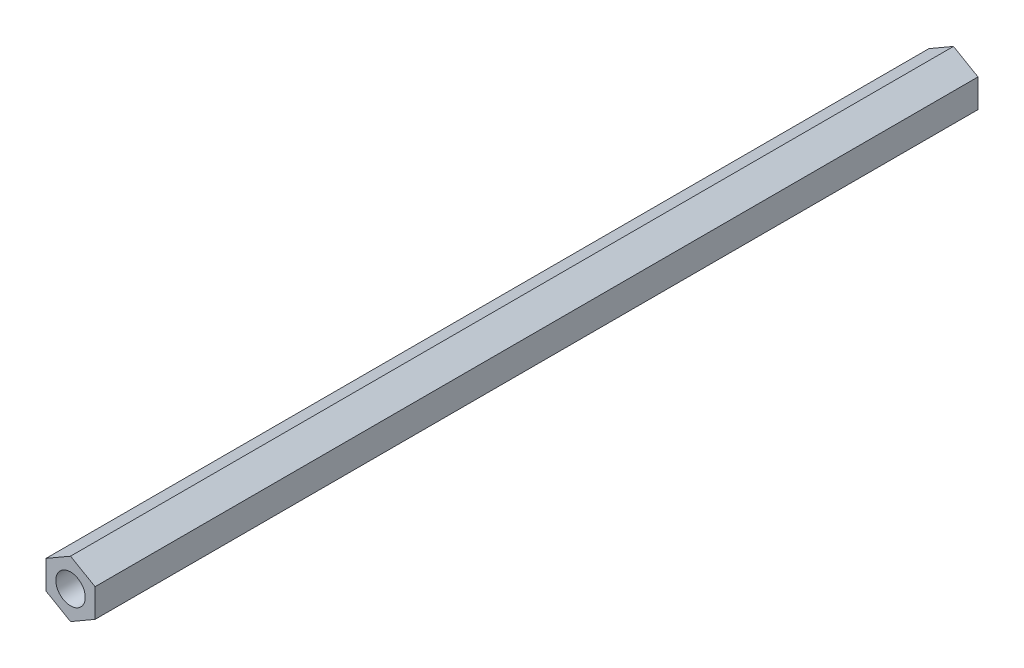
from build123d import *

# Parameters (mm, degrees)
ESQUISSE1_R        = 1.5
BOSS_EXTRU_1_DEPTH = 90


with BuildPart() as part:
    # Esquisse1 → Boss.-Extru.1 (new body)
    with BuildSketch(Plane.XY):
        Polygon((0, 2.886751346), (-2.5, 1.443375673), (-2.5, -1.443375673), (0, -2.886751346), (2.5, -1.443375673), (2.5, 1.443375673), align=None)
        Circle(ESQUISSE1_R, mode=Mode.SUBTRACT)
    extrude(amount=BOSS_EXTRU_1_DEPTH)


solid = part.part
